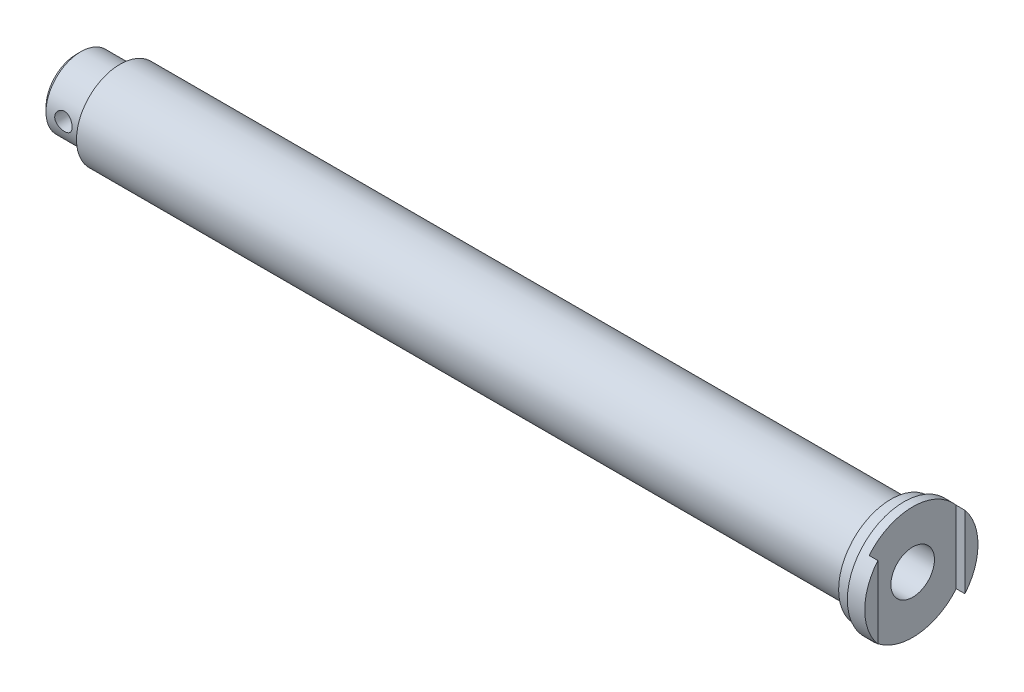
from build123d import *

# Parameters (mm, degrees)
SKETCH4_W               = 10
SKETCH4_H               = 13
CUT_EXTRUDE2_DEPTH      = 1
M6_TAPPED_HOLE1_D       = 5
M6_TAPPED_HOLE1_DEPTH   = 10
M6_TAPPED_HOLE1_TIP     = 1.502151548
SKETCH8_R               = 1
CUT_EXTRUDE3_DEPTH      = 7.5
CUT_EXTRUDE3_DEPTH_BACK = 7.5
CHAMFER1_SIZE           = 0.5


with BuildPart() as part:
    # Sketch1 → Revolve1 (revolve)
    with BuildSketch(Plane.XY):
        Polygon((-97, 0), (-97, 4), (-92, 4), (-92, 5), (-3.5, 5), (-3.5, 6), (-2, 6), (-2, 6.5), (0, 6.5), (0, 0), align=None)
    revolve(axis=Axis((0, 0, 0), (1, 0, 0)))

    # Sketch4 → Cut-Extrude2 (cut)
    with BuildSketch(Plane(origin=(0, 0, 0), x_dir=(0, 0, -1), z_dir=(1, 0, 0))):
        Rectangle(SKETCH4_W, SKETCH4_H)
    extrude(amount=-CUT_EXTRUDE2_DEPTH, mode=Mode.SUBTRACT)

    # M6 Tapped Hole1
    with Locations(Plane(origin=(-1, 0, 0), x_dir=(0, 0, -1), z_dir=(1, 0, 0))):
        with Locations((0, 0)):
            Hole(M6_TAPPED_HOLE1_D / 2, depth=M6_TAPPED_HOLE1_DEPTH)
            with Locations((0, 0, -(M6_TAPPED_HOLE1_DEPTH + M6_TAPPED_HOLE1_TIP / 2))):  # 118° drill point
                Cone(0, M6_TAPPED_HOLE1_D / 2, M6_TAPPED_HOLE1_TIP, mode=Mode.SUBTRACT)

    # Sketch8 → Cut-Extrude3 (cut, two sides)
    with BuildSketch(Plane.XY) as cut_extrude3_sk:
        with Locations((-94.5, 0)):
            Circle(SKETCH8_R)
    extrude(amount=CUT_EXTRUDE3_DEPTH, mode=Mode.SUBTRACT)
    extrude(cut_extrude3_sk.sketch, amount=-CUT_EXTRUDE3_DEPTH_BACK, mode=Mode.SUBTRACT)

    # Chamfer1
    chamfer1_edges = [part.edges().sort_by_distance(p)[0] for p in [
        (-97, -4, 0),
    ]]
    chamfer(chamfer1_edges, length=CHAMFER1_SIZE)


solid = part.part
